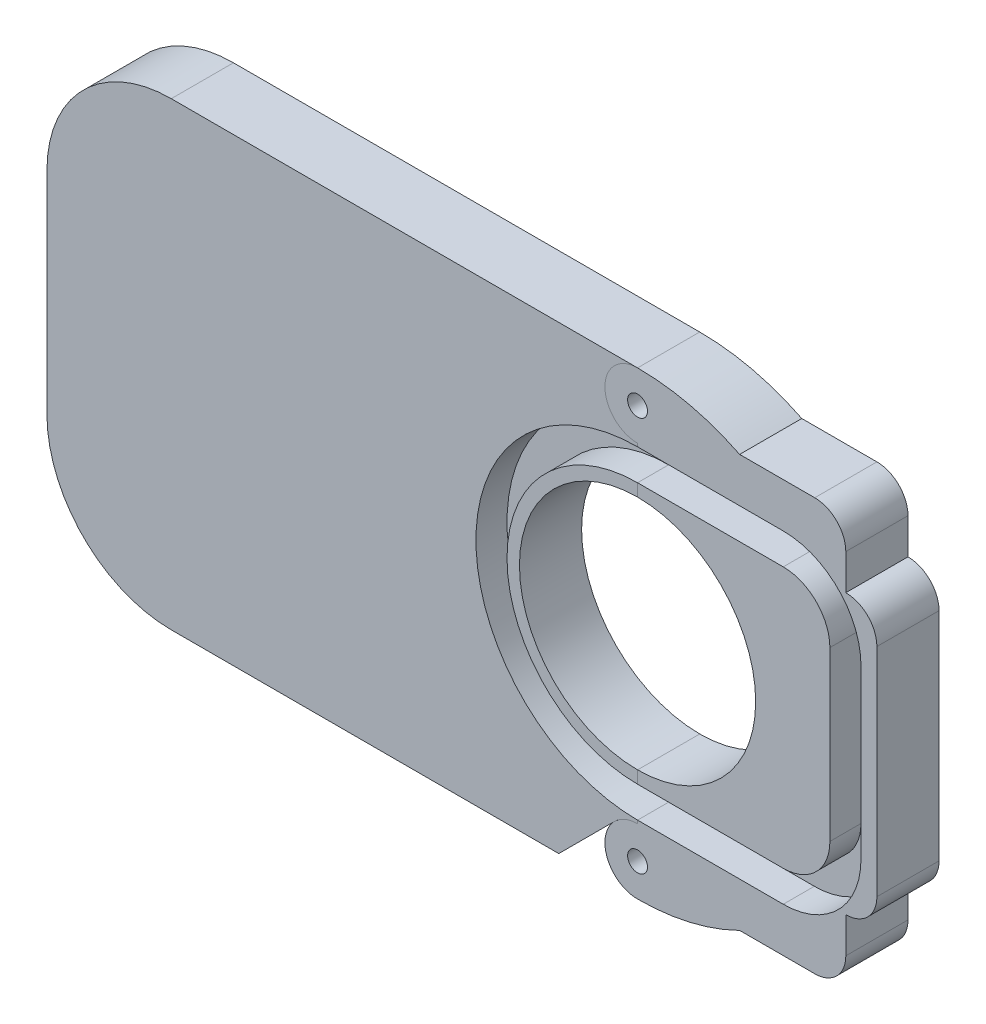
from build123d import *

# Parameters (mm, degrees)
SKETCH1_R           = 1.6
BOSS_EXTRUDE1_DEPTH = 10
BOSS_EXTRUDE2_DEPTH = 10
CUT_EXTRUDE3_DEPTH  = 5
CUT_EXTRUDE4_DEPTH  = 5


with BuildPart() as part:
    # Sketch1 → Boss-Extrude1 (new body)
    with BuildSketch(Plane.XY):
        with BuildLine():
            ThreePointArc((-48.126591176, -199.167340501), (-50.135679618, -199.566972948), (-51.838902692, -200.7050299))
            ThreePointArc((-51.838902692, -200.7050299), (-52.976960936, -206.426431151), (-48.126591176, -209.667344916))
            ThreePointArc((-48.126591176, -209.667344916), (-39.694447805, -208.6937098), (-31.706079023, -205.824045816))
            Line((-31.706079023, -205.824045816), (-19.628209226, -205.824045816))
            ThreePointArc((-19.628209226, -205.824045816), (-16.09267532, -204.359579722), (-14.628209226, -200.824045816))
            Line((-14.628209226, -200.824045816), (-14.628209226, -195.09257804))
            ThreePointArc((-14.628209226, -195.09257804), (-11.09267532, -193.628111946), (-9.628209226, -190.09257804))
            Line((-9.628209226, -190.09257804), (-9.628209226, -155.239636863))
            ThreePointArc((-9.628209226, -155.239636863), (-11.092539014, -151.705471905), (-14.626591176, -150.240869913))
            Line((-14.626591176, -150.240869913), (-14.626591176, -144.510294404))
            ThreePointArc((-14.626591176, -144.510294404), (-16.09105727, -140.974760498), (-19.626591176, -139.510294404))
            Line((-19.626591176, -139.510294404), (-31.706777105, -139.510294404))
            ThreePointArc((-31.706777105, -139.510294404), (-39.694826995, -136.640886987), (-48.126591176, -135.667340501))
            ThreePointArc((-48.126591176, -135.667340501), (-53.376591176, -140.917340501), (-48.126591176, -146.167340501))
            Line((-48.126591176, -146.167340501), (-48.126591176, -153.667340501))
            ThreePointArc((-48.126591176, -153.667340501), (-34.691562334, -159.232311659), (-29.126591176, -172.667340501))
            ThreePointArc((-29.126591176, -172.667340501), (-34.691562334, -186.102369344), (-48.126591176, -191.667340501))
            Line((-48.126591176, -191.667340501), (-48.126591176, -199.167340501))
        make_face()
        with Locations((-48.126591176, -204.417342709)):
            Circle(SKETCH1_R, mode=Mode.SUBTRACT)
        with Locations((-48.126591176, -140.917340501)):
            Circle(SKETCH1_R, mode=Mode.SUBTRACT)
    extrude(amount=BOSS_EXTRUDE1_DEPTH)

    # Sketch5 → Cut-Extrude4 (cut)
    with BuildSketch(Plane.XY.offset(10)):
        with BuildLine():
            Line((-48.126591176, -193.667340501), (-48.126591176, -198.667340501))
            Line((-48.126591176, -198.667340501), (-24.688746804, -198.667340501))
            ThreePointArc((-24.688746804, -198.667340501), (-15.849912039, -195.006175266), (-12.188746804, -186.167340501))
            Line((-12.188746804, -186.167340501), (-12.188746804, -159.167340501))
            ThreePointArc((-12.188746804, -159.167340501), (-15.849912039, -150.328505736), (-24.688746804, -146.667340501))
            Line((-24.688746804, -146.667340501), (-48.126591176, -146.667340501))
            Line((-48.126591176, -146.667340501), (-48.126591176, -151.667340501))
            Line((-48.126591176, -151.667340501), (-24.688746804, -151.667340501))
            ThreePointArc((-24.688746804, -151.667340501), (-19.385445945, -153.864039642), (-17.188746804, -159.167340501))
            Line((-17.188746804, -159.167340501), (-17.188746804, -186.167340501))
            ThreePointArc((-17.188746804, -186.167340501), (-19.385445945, -191.47064136), (-24.688746804, -193.667340501))
            Line((-24.688746804, -193.667340501), (-48.126591176, -193.667340501))
        make_face()
    extrude(amount=-CUT_EXTRUDE4_DEPTH, mode=Mode.SUBTRACT)


with BuildPart() as body_2:
    # Sketch1_6 → Boss-Extrude2 (new body)
    with BuildSketch(Plane.XY):
        with BuildLine():
            Line((-60.80122083, -209.667344916), (-51.838902692, -200.7050299))
            ThreePointArc((-51.838902692, -200.7050299), (-50.135679618, -199.566972948), (-48.126591176, -199.167340501))
            Line((-48.126591176, -199.167340501), (-48.126591176, -191.667340501))
            ThreePointArc((-48.126591176, -191.667340501), (-67.126591176, -172.667340501), (-48.126591176, -153.667340501))
            Line((-48.126591176, -153.667340501), (-48.126591176, -146.167340501))
            ThreePointArc((-48.126591176, -146.167340501), (-53.376591176, -140.917340501), (-48.126591176, -135.667340501))
            Line((-48.126591176, -135.667340501), (-123.133338168, -135.667340501))
            ThreePointArc((-123.133338168, -135.667340501), (-137.275475586, -141.525206282), (-143.133338225, -155.667345001))
            Line((-143.133338225, -155.667345001), (-143.133338225, -189.667345001))
            ThreePointArc((-143.133338225, -189.667345001), (-137.275473788, -203.8094806), (-123.13333814, -209.667344916))
            Line((-123.13333814, -209.667344916), (-60.80122083, -209.667344916))
        make_face()
    extrude(amount=BOSS_EXTRUDE2_DEPTH)

    # Sketch2 → Cut-Extrude3 (cut)
    with BuildSketch(Plane(origin=(0, 0, 10), x_dir=(-1, 0, 0), z_dir=(0, 0, -1))):
        with BuildLine():
            Line((48.126591176, -146.667340501), (48.126591176, -151.667340501))
            ThreePointArc((48.126591176, -151.667340501), (69.126591176, -172.667340501), (48.126591176, -193.667340501))
            Line((48.126591176, -193.667340501), (48.126591176, -198.667340501))
            ThreePointArc((48.126591176, -198.667340501), (74.126591176, -172.667340501), (48.126591176, -146.667340501))
        make_face()
    extrude(amount=CUT_EXTRUDE3_DEPTH, mode=Mode.SUBTRACT)


solid = Compound([part.part, body_2.part])
